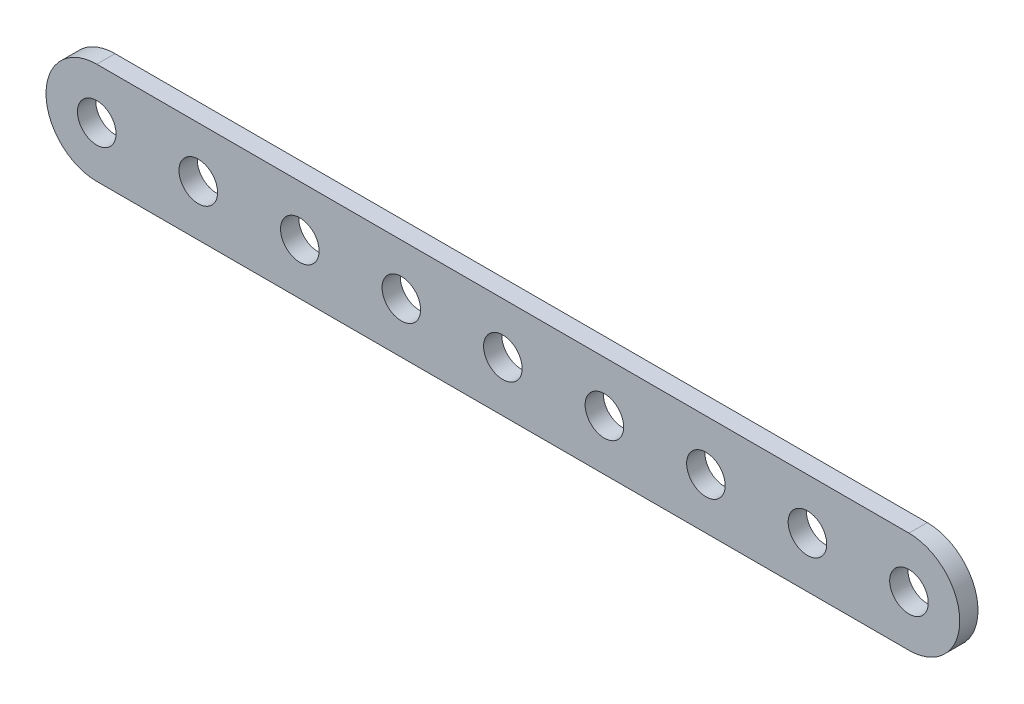
from build123d import *

# Parameters (mm, degrees)
EXTRUDE1_DEPTH     = 2.286
SKETCH2_R          = 2.413
CUT_EXTRUDE1_DEPTH = 3.286
LPATTERN1_COUNT    = 9
LPATTERN1_PITCH    = 12.7


with BuildPart() as part:
    # Sketch1 → Extrude1 (new body)
    with BuildSketch(Plane.XY):
        with BuildLine():
            Line((-50.8, -6.35), (50.8, -6.35))
            ThreePointArc((50.8, -6.35), (57.15, 0), (50.8, 6.35))
            Line((50.8, 6.35), (-50.8, 6.35))
            ThreePointArc((-50.8, 6.35), (-57.15, 0), (-50.8, -6.35))
        make_face()
    extrude(amount=EXTRUDE1_DEPTH)

    # Sketch2 → Cut-Extrude1 (cut, through all)
    with BuildSketch(Plane.XY.offset(2.286)):
        with Locations((-50.8, 0)):
            Circle(SKETCH2_R)
    cut_extrude1 = extrude(amount=-CUT_EXTRUDE1_DEPTH, mode=Mode.SUBTRACT)

    # LPattern1: Cut-Extrude1 ×9
    with Locations(*[(i * LPATTERN1_PITCH, 0, 0) for i in range(1, LPATTERN1_COUNT)]):
        add(cut_extrude1, mode=Mode.SUBTRACT)


solid = part.part
